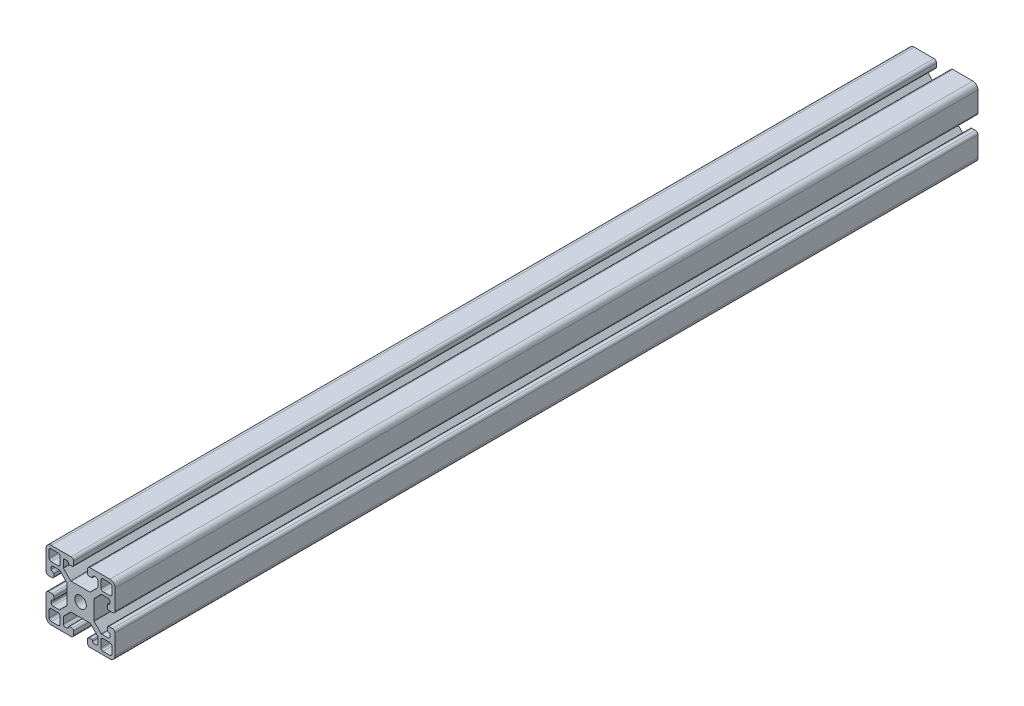
from build123d import *

# Parameters (mm, degrees)
SKETCH1_R           = 3.35
BOSS_EXTRUDE1_DEPTH = 500


with BuildPart() as part:
    # Sketch1 → Boss-Extrude1 (new body)
    with BuildSketch(Plane.XY):
        with BuildLine():
            Line((-9.853553391, -11.978553391), (-5.771446609, -7.896446609))
            ThreePointArc((-5.771446609, -7.896446609), (-5.609234935, -7.788060234), (-5.417893219, -7.75))
            Line((-5.417893219, -7.75), (5.417893219, -7.75))
            ThreePointArc((5.417893219, -7.75), (5.609234935, -7.788060234), (5.771446609, -7.896446609))
            Line((5.771446609, -7.896446609), (9.853553391, -11.978553391))
            ThreePointArc((9.853553391, -11.978553391), (9.961939766, -12.140765065), (10, -12.332106781))
            Line((10, -12.332106781), (10, -16))
            ThreePointArc((10, -16), (9.707106781, -16.707106781), (9, -17))
            Line((9, -17), (8, -17))
            ThreePointArc((8, -17), (7.292893219, -16.707106781), (7, -16))
            ThreePointArc((7, -16), (6.853553391, -15.646446609), (6.5, -15.5))
            Line((6.5, -15.5), (5, -15.5))
            ThreePointArc((5, -15.5), (4.292893219, -15.792893219), (4, -16.5))
            Line((4, -16.5), (4, -18.5))
            ThreePointArc((4, -18.5), (4.439339828, -19.560660172), (5.5, -20))
            Line((5.5, -20), (17, -20))
            ThreePointArc((17, -20), (19.121320344, -19.121320344), (20, -17))
            Line((20, -17), (20, -5.5))
            ThreePointArc((20, -5.5), (19.560660172, -4.439339828), (18.5, -4))
            Line((18.5, -4), (16.5, -4))
            ThreePointArc((16.5, -4), (15.792893219, -4.292893219), (15.5, -5))
            Line((15.5, -5), (15.5, -6.5))
            ThreePointArc((15.5, -6.5), (15.646446609, -6.853553391), (16, -7))
            ThreePointArc((16, -7), (16.707106781, -7.292893219), (17, -8))
            Line((17, -8), (17, -9))
            ThreePointArc((17, -9), (16.707106781, -9.707106781), (16, -10))
            Line((16, -10), (12.332106781, -10))
            ThreePointArc((12.332106781, -10), (12.140765065, -9.961939766), (11.978553391, -9.853553391))
            Line((11.978553391, -9.853553391), (7.896446609, -5.771446609))
            ThreePointArc((7.896446609, -5.771446609), (7.788060234, -5.609234935), (7.75, -5.417893219))
            Line((7.75, -5.417893219), (7.75, 5.417893219))
            ThreePointArc((7.75, 5.417893219), (7.788060234, 5.609234935), (7.896446609, 5.771446609))
            Line((7.896446609, 5.771446609), (11.978553391, 9.853553391))
            ThreePointArc((11.978553391, 9.853553391), (12.140765065, 9.961939766), (12.332106781, 10))
            Line((12.332106781, 10), (16, 10))
            ThreePointArc((16, 10), (16.707106781, 9.707106781), (17, 9))
            Line((17, 9), (17, 8))
            ThreePointArc((17, 8), (16.707106781, 7.292893219), (16, 7))
            ThreePointArc((16, 7), (15.646446609, 6.853553391), (15.5, 6.5))
            Line((15.5, 6.5), (15.5, 5))
            ThreePointArc((15.5, 5), (15.792893219, 4.292893219), (16.5, 4))
            Line((16.5, 4), (18.5, 4))
            ThreePointArc((18.5, 4), (19.560660172, 4.439339828), (20, 5.5))
            Line((20, 5.5), (20, 17))
            ThreePointArc((20, 17), (19.121320344, 19.121320344), (17, 20))
            Line((17, 20), (5.5, 20))
            ThreePointArc((5.5, 20), (4.439339828, 19.560660172), (4, 18.5))
            Line((4, 18.5), (4, 16.5))
            ThreePointArc((4, 16.5), (4.292893219, 15.792893219), (5, 15.5))
            Line((5, 15.5), (6.5, 15.5))
            ThreePointArc((6.5, 15.5), (6.853553391, 15.646446609), (7, 16))
            ThreePointArc((7, 16), (7.292893219, 16.707106781), (8, 17))
            Line((8, 17), (9, 17))
            ThreePointArc((9, 17), (9.707106781, 16.707106781), (10, 16))
            Line((10, 16), (10, 12.332106781))
            ThreePointArc((10, 12.332106781), (9.961939766, 12.140765065), (9.853553391, 11.978553391))
            Line((9.853553391, 11.978553391), (5.771446609, 7.896446609))
            ThreePointArc((5.771446609, 7.896446609), (5.609234935, 7.788060234), (5.417893219, 7.75))
            Line((5.417893219, 7.75), (-5.417893219, 7.75))
            ThreePointArc((-5.417893219, 7.75), (-5.609234935, 7.788060234), (-5.771446609, 7.896446609))
            Line((-5.771446609, 7.896446609), (-9.853553391, 11.978553391))
            ThreePointArc((-9.853553391, 11.978553391), (-9.961939766, 12.140765065), (-10, 12.332106781))
            Line((-10, 12.332106781), (-10, 16))
            ThreePointArc((-10, 16), (-9.707106781, 16.707106781), (-9, 17))
            Line((-9, 17), (-8, 17))
            ThreePointArc((-8, 17), (-7.292893219, 16.707106781), (-7, 16))
            ThreePointArc((-7, 16), (-6.853553391, 15.646446609), (-6.5, 15.5))
            Line((-6.5, 15.5), (-5, 15.5))
            ThreePointArc((-5, 15.5), (-4.292893219, 15.792893219), (-4, 16.5))
            Line((-4, 16.5), (-4, 18.5))
            ThreePointArc((-4, 18.5), (-4.439339828, 19.560660172), (-5.5, 20))
            Line((-5.5, 20), (-17, 20))
            ThreePointArc((-17, 20), (-19.121320344, 19.121320344), (-20, 17))
            Line((-20, 17), (-20, 5.5))
            ThreePointArc((-20, 5.5), (-19.560660172, 4.439339828), (-18.5, 4))
            Line((-18.5, 4), (-16.5, 4))
            ThreePointArc((-16.5, 4), (-15.792893219, 4.292893219), (-15.5, 5))
            Line((-15.5, 5), (-15.5, 6.5))
            ThreePointArc((-15.5, 6.5), (-15.646446609, 6.853553391), (-16, 7))
            ThreePointArc((-16, 7), (-16.707106781, 7.292893219), (-17, 8))
            Line((-17, 8), (-17, 9))
            ThreePointArc((-17, 9), (-16.707106781, 9.707106781), (-16, 10))
            Line((-16, 10), (-12.332106781, 10))
            ThreePointArc((-12.332106781, 10), (-12.140765065, 9.961939766), (-11.978553391, 9.853553391))
            Line((-11.978553391, 9.853553391), (-7.896446609, 5.771446609))
            ThreePointArc((-7.896446609, 5.771446609), (-7.788060234, 5.609234935), (-7.75, 5.417893219))
            Line((-7.75, 5.417893219), (-7.75, -5.417893219))
            ThreePointArc((-7.75, -5.417893219), (-7.788060234, -5.609234935), (-7.896446609, -5.771446609))
            Line((-7.896446609, -5.771446609), (-11.978553391, -9.853553391))
            ThreePointArc((-11.978553391, -9.853553391), (-12.140765065, -9.961939766), (-12.332106781, -10))
            Line((-12.332106781, -10), (-16, -10))
            ThreePointArc((-16, -10), (-16.707106781, -9.707106781), (-17, -9))
            Line((-17, -9), (-17, -8))
            ThreePointArc((-17, -8), (-16.707106781, -7.292893219), (-16, -7))
            ThreePointArc((-16, -7), (-15.646446609, -6.853553391), (-15.5, -6.5))
            Line((-15.5, -6.5), (-15.5, -5))
            ThreePointArc((-15.5, -5), (-15.792893219, -4.292893219), (-16.5, -4))
            Line((-16.5, -4), (-18.5, -4))
            ThreePointArc((-18.5, -4), (-19.560660172, -4.439339828), (-20, -5.5))
            Line((-20, -5.5), (-20, -17))
            ThreePointArc((-20, -17), (-19.121320344, -19.121320344), (-17, -20))
            Line((-17, -20), (-5.5, -20))
            ThreePointArc((-5.5, -20), (-4.439339828, -19.560660172), (-4, -18.5))
            Line((-4, -18.5), (-4, -16.5))
            ThreePointArc((-4, -16.5), (-4.292893219, -15.792893219), (-5, -15.5))
            Line((-5, -15.5), (-6.5, -15.5))
            ThreePointArc((-6.5, -15.5), (-6.853553391, -15.646446609), (-7, -16))
            ThreePointArc((-7, -16), (-7.292893219, -16.707106781), (-8, -17))
            Line((-8, -17), (-9, -17))
            ThreePointArc((-9, -17), (-9.707106781, -16.707106781), (-10, -16))
            Line((-10, -16), (-10, -12.332106781))
            ThreePointArc((-10, -12.332106781), (-9.961939766, -12.140765065), (-9.853553391, -11.978553391))
        make_face()
        Circle(SKETCH1_R, mode=Mode.SUBTRACT)
        with BuildLine():
            Line((-17, 11.78), (-13, 11.78))
            ThreePointArc((-13, 11.78), (-12.137329727, 12.137329727), (-11.78, 13))
            Line((-11.78, 13), (-11.78, 17))
            ThreePointArc((-11.78, 17), (-12.137329727, 17.862670273), (-13, 18.22))
            Line((-13, 18.22), (-17, 18.22))
            ThreePointArc((-17, 18.22), (-17.862670273, 17.862670273), (-18.22, 17))
            Line((-18.22, 17), (-18.22, 13))
            ThreePointArc((-18.22, 13), (-17.862670273, 12.137329727), (-17, 11.78))
        make_face(mode=Mode.SUBTRACT)
        with BuildLine():
            Line((-18.22, -13), (-18.22, -17))
            ThreePointArc((-18.22, -17), (-17.862670273, -17.862670273), (-17, -18.22))
            Line((-17, -18.22), (-13, -18.22))
            ThreePointArc((-13, -18.22), (-12.137329727, -17.862670273), (-11.78, -17))
            Line((-11.78, -17), (-11.78, -13))
            ThreePointArc((-11.78, -13), (-12.137329727, -12.137329727), (-13, -11.78))
            Line((-13, -11.78), (-17, -11.78))
            ThreePointArc((-17, -11.78), (-17.862670273, -12.137329727), (-18.22, -13))
        make_face(mode=Mode.SUBTRACT)
        with BuildLine():
            Line((13, -18.22), (17, -18.22))
            ThreePointArc((17, -18.22), (17.862670273, -17.862670273), (18.22, -17))
            Line((18.22, -17), (18.22, -13))
            ThreePointArc((18.22, -13), (17.862670273, -12.137329727), (17, -11.78))
            Line((17, -11.78), (13, -11.78))
            ThreePointArc((13, -11.78), (12.137329727, -12.137329727), (11.78, -13))
            Line((11.78, -13), (11.78, -17))
            ThreePointArc((11.78, -17), (12.137329727, -17.862670273), (13, -18.22))
        make_face(mode=Mode.SUBTRACT)
        with BuildLine():
            Line((18.22, 13), (18.22, 17))
            ThreePointArc((18.22, 17), (17.862670273, 17.862670273), (17, 18.22))
            Line((17, 18.22), (13, 18.22))
            ThreePointArc((13, 18.22), (12.137329727, 17.862670273), (11.78, 17))
            Line((11.78, 17), (11.78, 13))
            ThreePointArc((11.78, 13), (12.137329727, 12.137329727), (13, 11.78))
            Line((13, 11.78), (17, 11.78))
            ThreePointArc((17, 11.78), (17.862670273, 12.137329727), (18.22, 13))
        make_face(mode=Mode.SUBTRACT)
    extrude(amount=BOSS_EXTRUDE1_DEPTH)


solid = part.part
